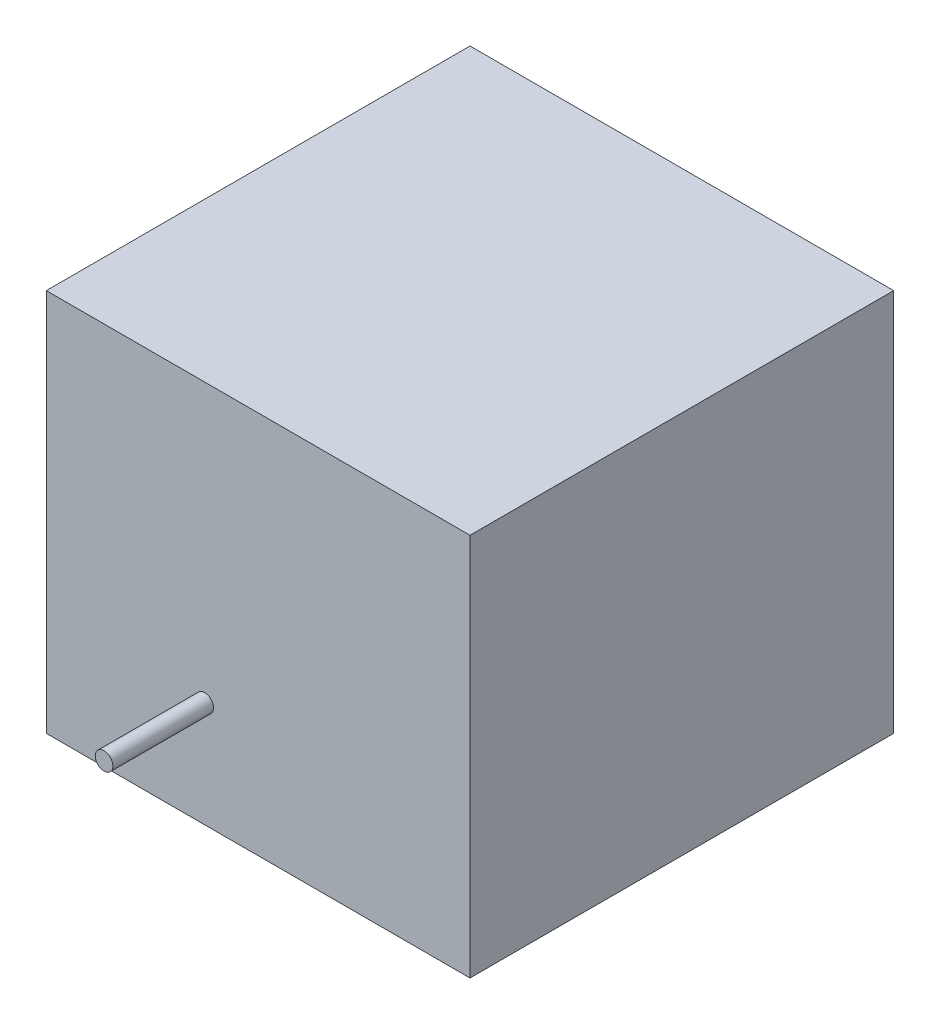
from build123d import *

# Parameters (mm, degrees)
SKETCH2_W           = 42.1
SKETCH2_H           = 42.1
BOSS_EXTRUDE1_DEPTH = 38.1
SKETCH4_R           = 0.875
BOSS_EXTRUDE2_DEPTH = 10
SKETCH5_R           = 0.875
BOSS_EXTRUDE3_DEPTH = 15


with BuildPart() as part:
    # Sketch2 → Boss-Extrude1 (new body)
    with BuildSketch(Plane(origin=(0, 0, 0), x_dir=(1, 0, 0), z_dir=(0, 1, 0))):
        with Locations((21.05, 21.05)):
            Rectangle(SKETCH2_W, SKETCH2_H)
    extrude(amount=BOSS_EXTRUDE1_DEPTH)

    # Sketch4 → Boss-Extrude2 (add)
    with BuildSketch(Plane.XY):
        with Locations((15.74, 10.5)):
            Circle(SKETCH4_R)
    extrude(amount=BOSS_EXTRUDE2_DEPTH)

    # Sketch5 → Boss-Extrude3 (add)
    with BuildSketch(Plane(origin=(0, 0, -42.1), x_dir=(-1, 0, 0), z_dir=(0, 0, -1))):
        with Locations((-15.74, 10.5)):
            Circle(SKETCH5_R)
    extrude(amount=BOSS_EXTRUDE3_DEPTH)


solid = part.part
